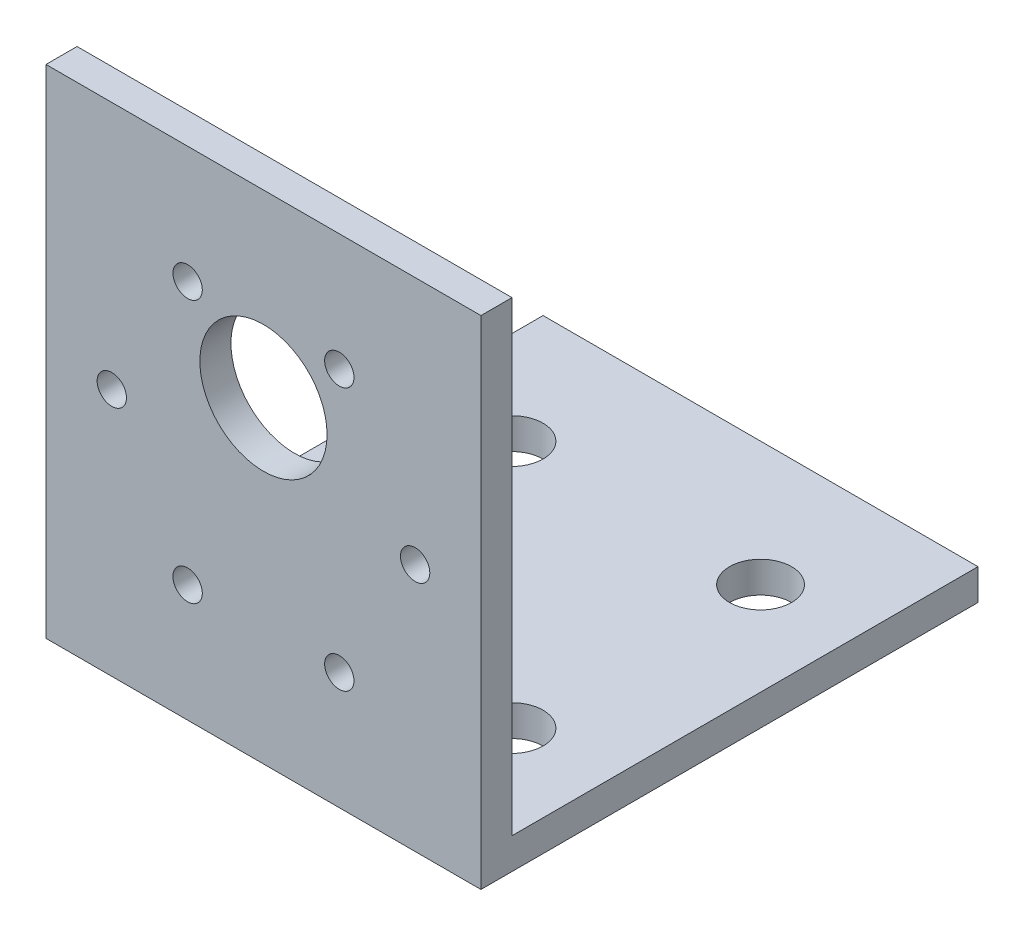
from build123d import *

# Parameters (mm, degrees)
SKETCH1_W           = 44.45
SKETCH1_H           = 50.8
SKETCH1_R           = 6.5
SKETCH1_R_2         = 1.5
BOSS_EXTRUDE1_DEPTH = 3.175
SKETCH2_W           = 44.45
SKETCH2_H           = 3.175
BOSS_EXTRUDE2_DEPTH = 47.625
SKETCH3_R           = 3.175
CUT_EXTRUDE1_DEPTH  = 4.175


with BuildPart() as part:
    # Sketch1 → Boss-Extrude1 (new body)
    with BuildSketch(Plane.XY):
        with Locations((22.225, 25.4)):
            Rectangle(SKETCH1_W, SKETCH1_H)
        with Locations((22.225, 32.4)):
            Circle(SKETCH1_R, mode=Mode.SUBTRACT)
        with Locations((6.725, 25.4)):
            Circle(SKETCH1_R_2, mode=Mode.SUBTRACT)
        with Locations((37.725, 25.4)):
            Circle(SKETCH1_R_2, mode=Mode.SUBTRACT)
        with Locations((29.975, 11.976606241)):
            Circle(SKETCH1_R_2, mode=Mode.SUBTRACT)
        with Locations((14.475, 11.976606241)):
            Circle(SKETCH1_R_2, mode=Mode.SUBTRACT)
        with Locations((14.475, 38.823393759)):
            Circle(SKETCH1_R_2, mode=Mode.SUBTRACT)
        with Locations((29.975, 38.823393759)):
            Circle(SKETCH1_R_2, mode=Mode.SUBTRACT)
    extrude(amount=BOSS_EXTRUDE1_DEPTH)

    # Sketch2 → Boss-Extrude2 (add)
    with BuildSketch(Plane(origin=(0, 0, 0), x_dir=(-1, 0, 0), z_dir=(0, 0, -1))):
        with Locations((-22.225, 1.5875)):
            Rectangle(SKETCH2_W, SKETCH2_H)
    extrude(amount=BOSS_EXTRUDE2_DEPTH)

    # Sketch3 → Cut-Extrude1 (cut, through all)
    with BuildSketch(Plane(origin=(0, 3.175, 0), x_dir=(1, 0, 0), z_dir=(0, 1, 0))):
        with Locations((34.925, 9.525)):
            Circle(SKETCH3_R)
        with Locations((34.925, 34.925)):
            Circle(SKETCH3_R)
        with Locations((9.525, 9.525)):
            Circle(SKETCH3_R)
        with Locations((9.525, 34.925)):
            Circle(SKETCH3_R)
    extrude(amount=-CUT_EXTRUDE1_DEPTH, mode=Mode.SUBTRACT)


solid = part.part
